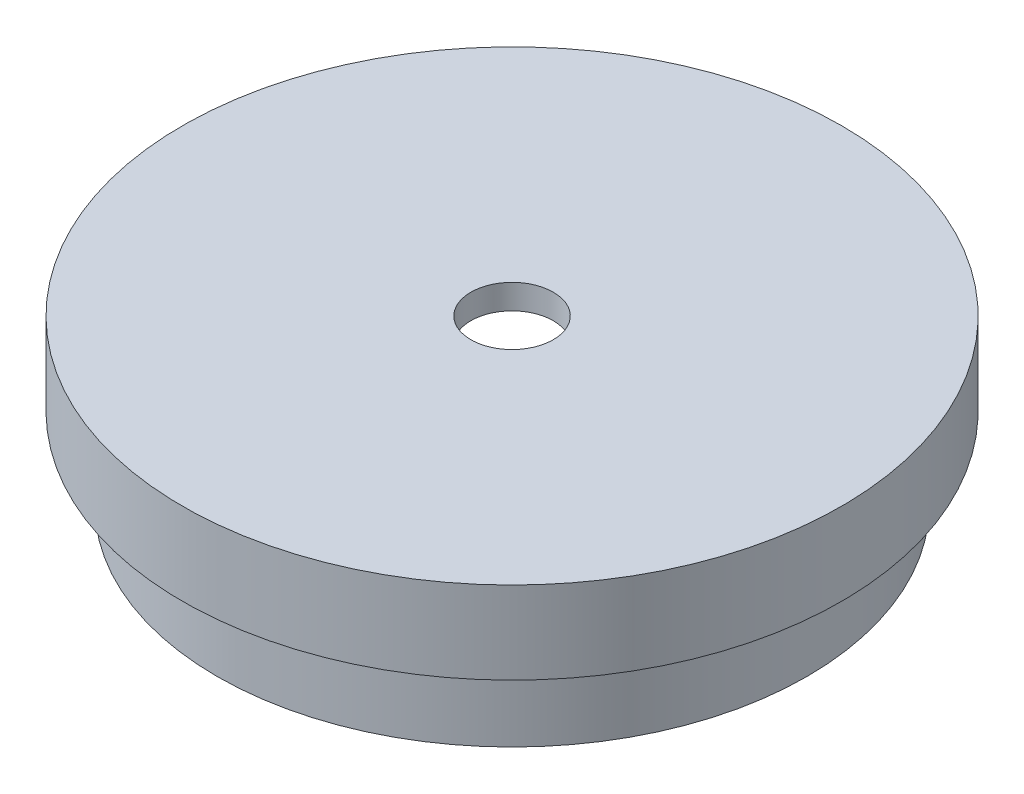
from build123d import *


with BuildPart() as part:
    # Sketch1 → Revolve1 (revolve)
    with BuildSketch(Plane.XY):
        Polygon((17.9, 0), (17.9, 5), (20, 5), (20, 10), (2.5, 10), (2.5, 8.5), (16.4, 8.5), (16.4, 0), align=None)
    revolve(axis=Axis((0, 0, 0), (0, 1, 0)))


solid = part.part
